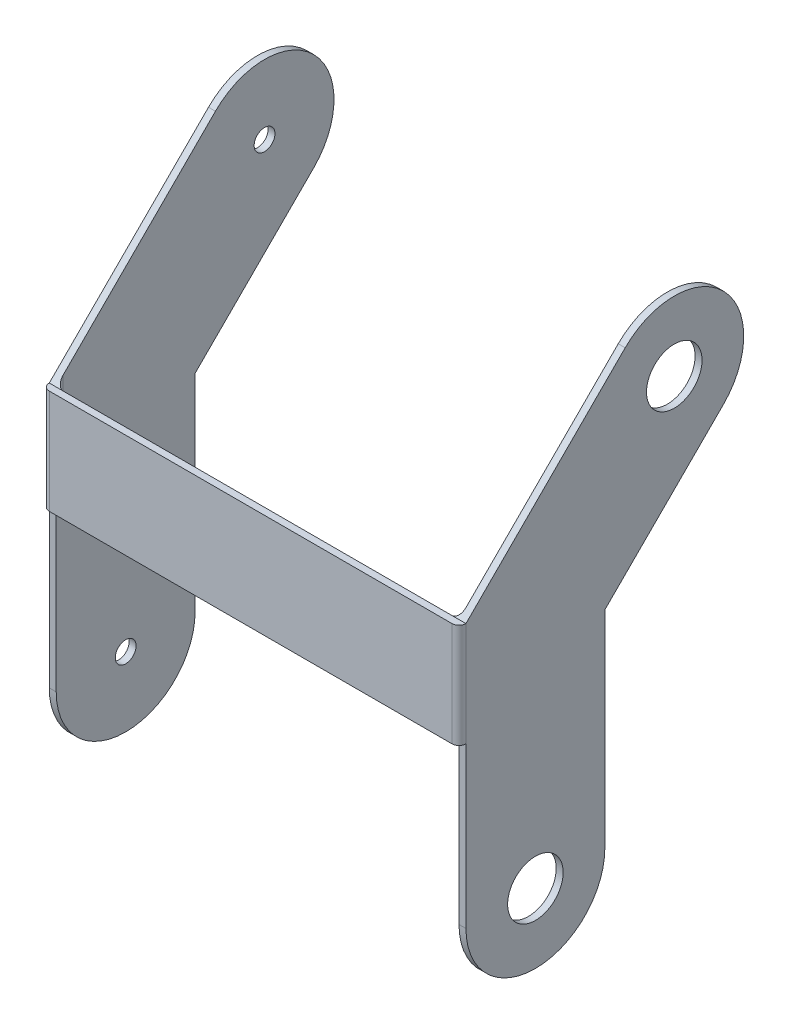
from build123d import *

# Parameters (mm, degrees)
SKETCH1_R           = 1.5
BOSS_EXTRUDE1_DEPTH = 1
BOSS_EXTRUDE2_START = -1
SKETCH2_W           = 1
SKETCH2_H           = 15
BOSS_EXTRUDE2_DEPTH = 30
FILLET1_R           = 1
CUT_EXTRUDE1_REACH  = 62
SKETCH3_R           = 4


with BuildPart() as part:
    # Sketch1 → Boss-Extrude1 (new body)
    with BuildSketch(Plane(origin=(0, 0, 0), x_dir=(0, 0, -1), z_dir=(1, 0, 0))):
        with BuildLine():
            Line((0, 0), (22.928644487, 22.928644487))
            ThreePointArc((22.928644487, 22.928644487), (37.07078011, 22.928644487), (37.07078011, 8.786508863))
            Line((37.07078011, 8.786508863), (20, -8.284271247))
            Line((20, -8.284271247), (20, -38.019))
            ThreePointArc((20, -38.019), (10, -48.019), (0, -38.019))
            Line((0, -38.019), (0, 0))
        make_face()
        with Locations((29.999712299, 15.857576675)):
            Circle(SKETCH1_R, mode=Mode.SUBTRACT)
        with Locations((10, -38.019)):
            Circle(SKETCH1_R, mode=Mode.SUBTRACT)
    boss_extrude1 = extrude(amount=BOSS_EXTRUDE1_DEPTH)

    # Sketch2 → Boss-Extrude2 (add)
    with BuildSketch(Plane(origin=(1, 0, 0), x_dir=(0, 0, -1), z_dir=(1, 0, 0)).offset(BOSS_EXTRUDE2_START)):
        with Locations((-0.5, -7.5)):
            Rectangle(SKETCH2_W, SKETCH2_H)
    boss_extrude2 = extrude(amount=BOSS_EXTRUDE2_DEPTH)

    # Mirror2: Boss-Extrude1, Boss-Extrude2 across plane
    add(boss_extrude1.mirror(Plane.ZY.offset(-30)))
    add(boss_extrude2.mirror(Plane.ZY.offset(-30)))

    # Fillet1
    fillet1_edges = [part.edges().sort_by_distance(p)[0] for p in [
        (1, -7.5, 0),
        (59, -7.5, 0),
        (0, -7.5, 1),
        (60, -7.5, 1),
    ]]
    fillet(fillet1_edges, radius=FILLET1_R)

    # Sketch3 → Cut-Extrude1 (cut, up to next)
    with BuildSketch(Plane(origin=(60, 0, 0), x_dir=(0, 0, -1), z_dir=(1, 0, 0)), mode=Mode.PRIVATE) as cut_extrude1_sk1:
        with Locations((29.999712299, 15.857576675)):
            Circle(SKETCH3_R)
    cut_extrude1_tool1 = extrude(cut_extrude1_sk1.sketch, amount=-CUT_EXTRUDE1_REACH, mode=Mode.PRIVATE) & part.part
    add(cut_extrude1_tool1.solids().sort_by_distance((60, 15.857577, -29.999712))[0], mode=Mode.SUBTRACT)
    # Sketch3 → Cut-Extrude1 (cut, up to next)
    with BuildSketch(Plane(origin=(60, 0, 0), x_dir=(0, 0, -1), z_dir=(1, 0, 0)), mode=Mode.PRIVATE) as cut_extrude1_sk2:
        with Locations((10, -38.019)):
            Circle(SKETCH3_R)
    cut_extrude1_tool2 = extrude(cut_extrude1_sk2.sketch, amount=-CUT_EXTRUDE1_REACH, mode=Mode.PRIVATE) & part.part
    add(cut_extrude1_tool2.solids().sort_by_distance((60, -38.019, -10))[0], mode=Mode.SUBTRACT)


solid = part.part
